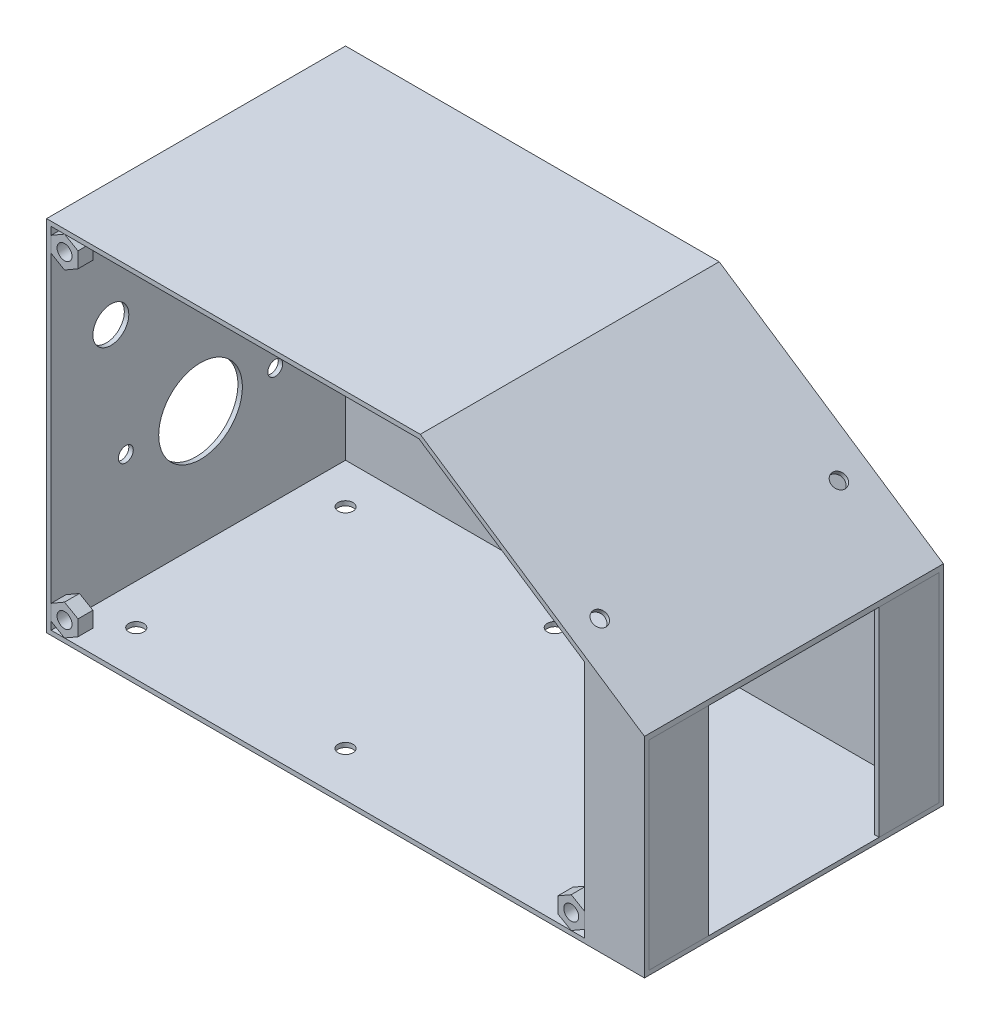
from build123d import *

# Parameters (mm, degrees)
BOSS_EXTRUDE1_DEPTH   = 100
SHELL1_T              = -1.5
BOSS_EXTRUDE2_DEPTH   = 1.5
SKETCH3_W             = 20
SKETCH3_H             = 66.697224362
BOSS_EXTRUDE7_DEPTH   = 1.5
BOSS_EXTRUDE7_2_DEPTH = 1.5
SKETCH4_R             = 14
SKETCH4_R_2           = 6
SKETCH4_R_3           = 2.5
CUT_EXTRUDE1_DEPTH    = 1.5
SKETCH5_R             = 2.5
CUT_EXTRUDE2_DEPTH    = 1.5
SKETCH6_R             = 2.5
BOSS_EXTRUDE8_DEPTH   = 5
BOSS_EXTRUDE8_2_DEPTH = 5
BOSS_EXTRUDE8_3_DEPTH = 5
SKETCH8_R             = 2.5
CUT_EXTRUDE3_DEPTH    = 1.5


with BuildPart() as part:
    # Sketch1 → Boss-Extrude1 (new body)
    with BuildSketch(Plane.XY):
        Polygon((0, 0), (0, 120), (125, 120), (200, 70), (200, 0), align=None)
    extrude(amount=BOSS_EXTRUDE1_DEPTH)

    # Shell1
    shell1_openings = [part.faces().sort_by_distance(p)[0] for p in [
        (105, 62, 100),
        (200, 35, 50),
    ]]
    offset(amount=SHELL1_T, openings=shell1_openings, kind=Kind.INTERSECTION)

    # Sketch2 → Boss-Extrude2 (add)
    with BuildSketch(Plane.XY.offset(100)):
        Polygon((200, 1.5), (200, 68.197224362), (180, 81.530557696), (180, 1.5), align=None)
    extrude(amount=-BOSS_EXTRUDE2_DEPTH)

    # Sketch4 → Cut-Extrude1 (cut)
    with BuildSketch(Plane.ZY):
        with Locations((50, 40)):
            Circle(SKETCH4_R)
        with Locations((20, 80)):
            Circle(SKETCH4_R_2)
        with Locations((80, 80)):
            Circle(SKETCH4_R_2)
        with Locations((25, 40)):
            Circle(SKETCH4_R_3)
        with Locations((75, 40)):
            Circle(SKETCH4_R_3)
        with Locations((50, 80)):
            Circle(SKETCH4_R_2)
    extrude(amount=-CUT_EXTRUDE1_DEPTH, mode=Mode.SUBTRACT)

    # Sketch5 → Cut-Extrude2 (cut)
    with BuildSketch(Plane(origin=(93.846153846, 140.769230769, 0), x_dir=(0.832050294, -0.554700196, 0), z_dir=(0.554700196, 0.832050294, 0))):
        with Locations((97.581045132, -10)):
            Circle(SKETCH5_R)
        with Locations((97.581045132, -90)):
            Circle(SKETCH5_R)
    extrude(amount=-CUT_EXTRUDE2_DEPTH, mode=Mode.SUBTRACT)

    # Sketch8 → Cut-Extrude3 (cut)
    with BuildSketch(Plane.XZ):
        with Locations((15, 85)):
            Circle(SKETCH8_R)
        with Locations((85, 85)):
            Circle(SKETCH8_R)
        with Locations((15, 15)):
            Circle(SKETCH8_R)
        with Locations((85, 15)):
            Circle(SKETCH8_R)
    extrude(amount=-CUT_EXTRUDE3_DEPTH, mode=Mode.SUBTRACT)


with BuildPart() as body_2:
    # Sketch3 → Boss-Extrude7 (new body)
    with BuildSketch(Plane(origin=(200, 0, 0), x_dir=(0, 0, -1), z_dir=(1, 0, 0))):
        with Locations((-11.5, 34.848612181)):
            Rectangle(SKETCH3_W, SKETCH3_H)
    extrude(amount=-BOSS_EXTRUDE7_DEPTH)


with BuildPart() as body_3:
    # Sketch3 → Boss-Extrude7 2 (new body)
    with BuildSketch(Plane(origin=(200, 0, 0), x_dir=(0, 0, -1), z_dir=(1, 0, 0))):
        with Locations((-88.5, 34.848612181)):
            Rectangle(SKETCH3_W, SKETCH3_H)
    extrude(amount=-BOSS_EXTRUDE7_2_DEPTH)


with BuildPart() as body_4:
    # Sketch6 → Boss-Extrude8 (new body)
    with BuildSketch(Plane.XY.offset(100)):
        Polygon((6, 1.5), (10.5, 4.098076211), (10.5, 9.294228634), (6, 11.892304845), (1.5, 9.294228634), (1.5, 4.098076211), align=None)
        with Locations((6, 6.696152423)):
            Circle(SKETCH6_R, mode=Mode.SUBTRACT)
    extrude(amount=-BOSS_EXTRUDE8_DEPTH)


with BuildPart() as body_5:
    # Sketch6 → Boss-Extrude8 2 (new body)
    with BuildSketch(Plane.XY.offset(100)):
        Polygon((10.5, 115.901923789), (10.5, 110.705771366), (6, 108.107695155), (1.5, 110.705771366), (1.5, 115.901923789), (6, 118.5), align=None)
        with Locations((6, 113.303847577)):
            Circle(SKETCH6_R, mode=Mode.SUBTRACT)
    extrude(amount=-BOSS_EXTRUDE8_2_DEPTH)


with BuildPart() as body_6:
    # Sketch6 → Boss-Extrude8 3 (new body)
    with BuildSketch(Plane.XY.offset(100)):
        Polygon((180, 4.098076211), (175.5, 1.5), (171, 4.098076211), (171, 9.294228634), (175.5, 11.892304845), (180, 9.294228634), align=None)
        with Locations((175.5, 6.696152423)):
            Circle(SKETCH6_R, mode=Mode.SUBTRACT)
    extrude(amount=-BOSS_EXTRUDE8_3_DEPTH)


solid = Compound([part.part, body_2.part, body_3.part, body_4.part, body_5.part, body_6.part])
